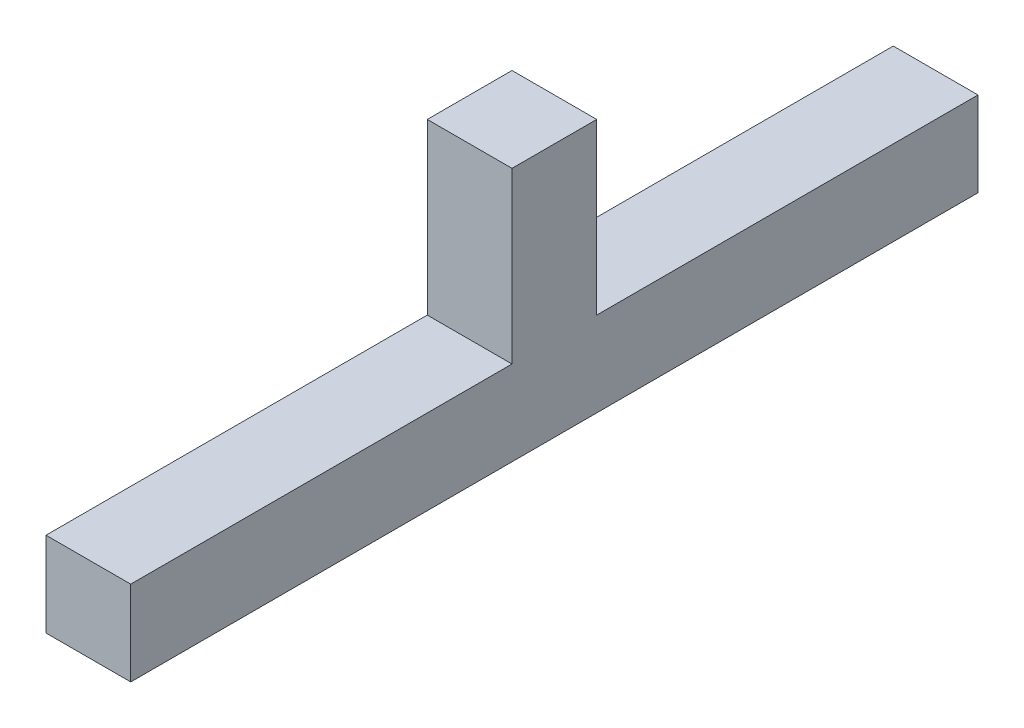
from build123d import *

# Parameters (mm, degrees)
BOSS_EXTRUDE4_DEPTH = 5


with BuildPart() as part:
    # Sketch1 → Boss-Extrude4 (new body)
    with BuildSketch(Plane(origin=(0, 0, 0), x_dir=(0, 0, -1), z_dir=(1, 0, 0))):
        Polygon((-50, 5), (-27.5, 5), (-27.5, 15), (-22.5, 15), (-22.5, 5), (0, 5), (0, 0), (-50, 0), align=None)
    extrude(amount=BOSS_EXTRUDE4_DEPTH)


solid = part.part
